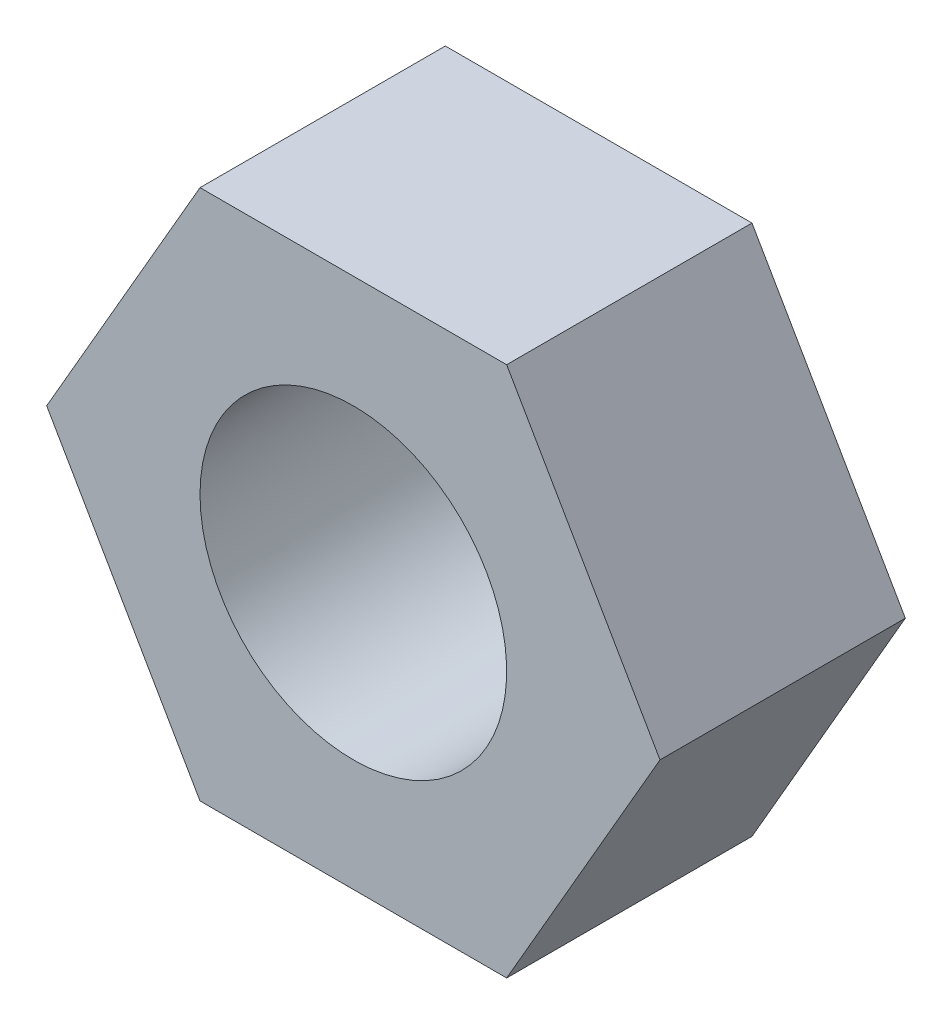
from build123d import *

# Parameters (mm, degrees)
SALIENTE_EXTRUIR1_DEPTH = 4
CROQUIS3_R              = 2.5
CORTAR_EXTRUIR1_DEPTH   = 5


with BuildPart() as part:
    # Croquis2 → Saliente-Extruir1 (new body)
    with BuildSketch(Plane.XY):
        Polygon((5, 0), (2.5, 4.330127019), (-2.5, 4.330127019), (-5, 0), (-2.5, -4.330127019), (2.5, -4.330127019), align=None)
    extrude(amount=SALIENTE_EXTRUIR1_DEPTH)

    # Croquis3 → Cortar-Extruir1 (cut, through all)
    with BuildSketch(Plane(origin=(0, 0, 0), x_dir=(-1, 0, 0), z_dir=(0, 0, -1))):
        Circle(CROQUIS3_R)
    extrude(amount=-CORTAR_EXTRUIR1_DEPTH, mode=Mode.SUBTRACT)


solid = part.part
